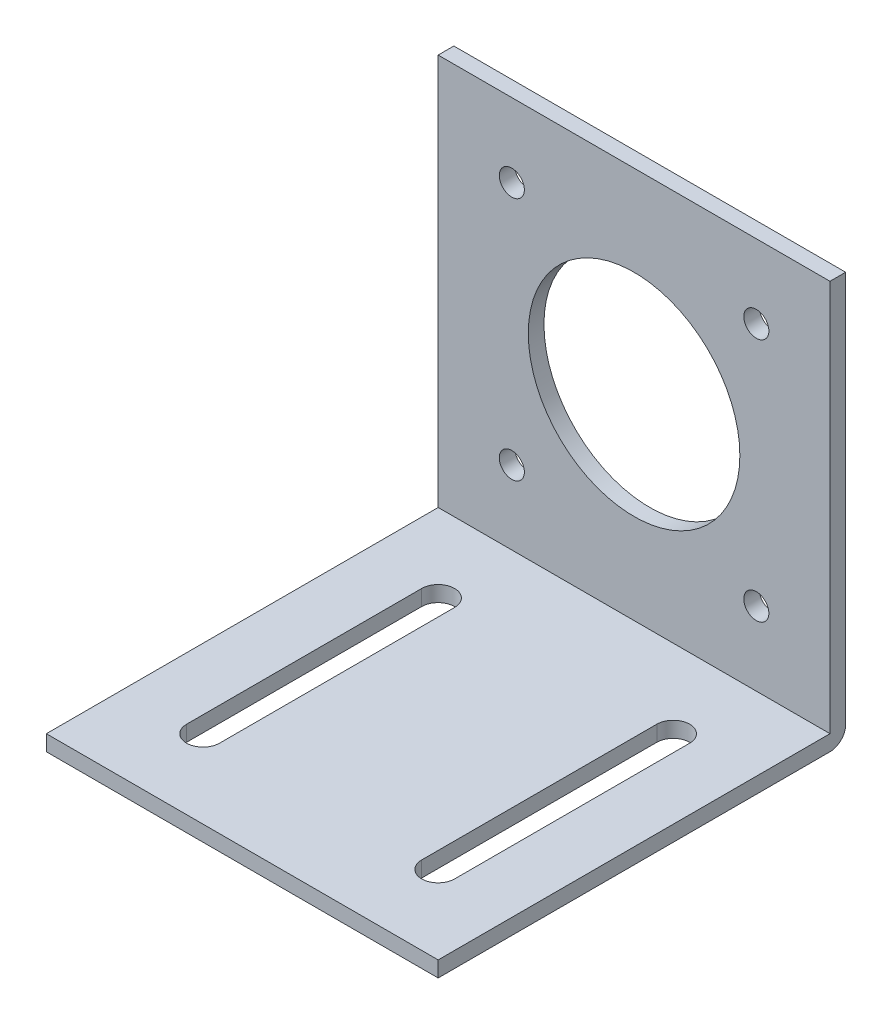
from build123d import *

# Parameters (mm, degrees)
SKETCH1_W           = 50
SKETCH1_H           = 50
BOSS_EXTRUDE1_DEPTH = 2
SKETCH2_W           = 50
SKETCH2_H           = 2
BOSS_EXTRUDE2_DEPTH = 52
CUT_EXTRUDE1_REACH  = 4
SKETCH3_R           = 1.6
SKETCH3_R_2         = 13.5
FILLET1_R           = 2


with BuildPart() as part:
    # Sketch1 → Boss-Extrude1 (new body)
    with BuildSketch(Plane(origin=(0, 0, 0), x_dir=(1, 0, 0), z_dir=(0, 1, 0))):
        Rectangle(SKETCH1_W, SKETCH1_H)
        with BuildLine():
            Line((-17.1, 15), (-17.1, -15))
            ThreePointArc((-17.1, -15), (-15, -17.1), (-12.9, -15))
            Line((-12.9, -15), (-12.9, 15))
            ThreePointArc((-12.9, 15), (-15, 17.1), (-17.1, 15))
        make_face(mode=Mode.SUBTRACT)
        with BuildLine():
            Line((17.1, 15), (17.1, -15))
            ThreePointArc((17.1, -15), (15, -17.1), (12.9, -15))
            Line((12.9, -15), (12.9, 15))
            ThreePointArc((12.9, 15), (15, 17.1), (17.1, 15))
        make_face(mode=Mode.SUBTRACT)
    extrude(amount=BOSS_EXTRUDE1_DEPTH)

    # Sketch2 → Boss-Extrude2 (add)
    with BuildSketch(Plane.XZ):
        with Locations((0, -26)):
            Rectangle(SKETCH2_W, SKETCH2_H)
    extrude(amount=-BOSS_EXTRUDE2_DEPTH)

    # Sketch3 → Cut-Extrude1 (cut, up to next)
    with BuildSketch(Plane.XY.offset(-25), mode=Mode.PRIVATE) as cut_extrude1_sk1:
        with Locations((-15.6, 42.6)):
            Circle(SKETCH3_R)
    cut_extrude1_tool1 = extrude(cut_extrude1_sk1.sketch, amount=-CUT_EXTRUDE1_REACH, mode=Mode.PRIVATE) & part.part
    add(cut_extrude1_tool1.solids().sort_by_distance((-15.6, 42.6, -25))[0], mode=Mode.SUBTRACT)
    # Sketch3 → Cut-Extrude1 (cut, up to next)
    with BuildSketch(Plane.XY.offset(-25), mode=Mode.PRIVATE) as cut_extrude1_sk2:
        with Locations((15.6, 42.6)):
            Circle(SKETCH3_R)
    cut_extrude1_tool2 = extrude(cut_extrude1_sk2.sketch, amount=-CUT_EXTRUDE1_REACH, mode=Mode.PRIVATE) & part.part
    add(cut_extrude1_tool2.solids().sort_by_distance((15.6, 42.6, -25))[0], mode=Mode.SUBTRACT)
    # Sketch3 → Cut-Extrude1 (cut, up to next)
    with BuildSketch(Plane.XY.offset(-25), mode=Mode.PRIVATE) as cut_extrude1_sk3:
        with Locations((15.6, 11.4)):
            Circle(SKETCH3_R)
    cut_extrude1_tool3 = extrude(cut_extrude1_sk3.sketch, amount=-CUT_EXTRUDE1_REACH, mode=Mode.PRIVATE) & part.part
    add(cut_extrude1_tool3.solids().sort_by_distance((15.6, 11.4, -25))[0], mode=Mode.SUBTRACT)
    # Sketch3 → Cut-Extrude1 (cut, up to next)
    with BuildSketch(Plane.XY.offset(-25), mode=Mode.PRIVATE) as cut_extrude1_sk4:
        with Locations((-15.6, 11.4)):
            Circle(SKETCH3_R)
    cut_extrude1_tool4 = extrude(cut_extrude1_sk4.sketch, amount=-CUT_EXTRUDE1_REACH, mode=Mode.PRIVATE) & part.part
    add(cut_extrude1_tool4.solids().sort_by_distance((-15.6, 11.4, -25))[0], mode=Mode.SUBTRACT)
    # Sketch3 → Cut-Extrude1 (cut, up to next)
    with BuildSketch(Plane.XY.offset(-25), mode=Mode.PRIVATE) as cut_extrude1_sk5:
        with Locations((0, 27)):
            Circle(SKETCH3_R_2)
    cut_extrude1_tool5 = extrude(cut_extrude1_sk5.sketch, amount=-CUT_EXTRUDE1_REACH, mode=Mode.PRIVATE) & part.part
    add(cut_extrude1_tool5.solids().sort_by_distance((0, 27, -25))[0], mode=Mode.SUBTRACT)

    # Fillet1
    fillet1_edges = [part.edges().sort_by_distance(p)[0] for p in [
        (0, 0, -27),
    ]]
    fillet(fillet1_edges, radius=FILLET1_R)


solid = part.part
